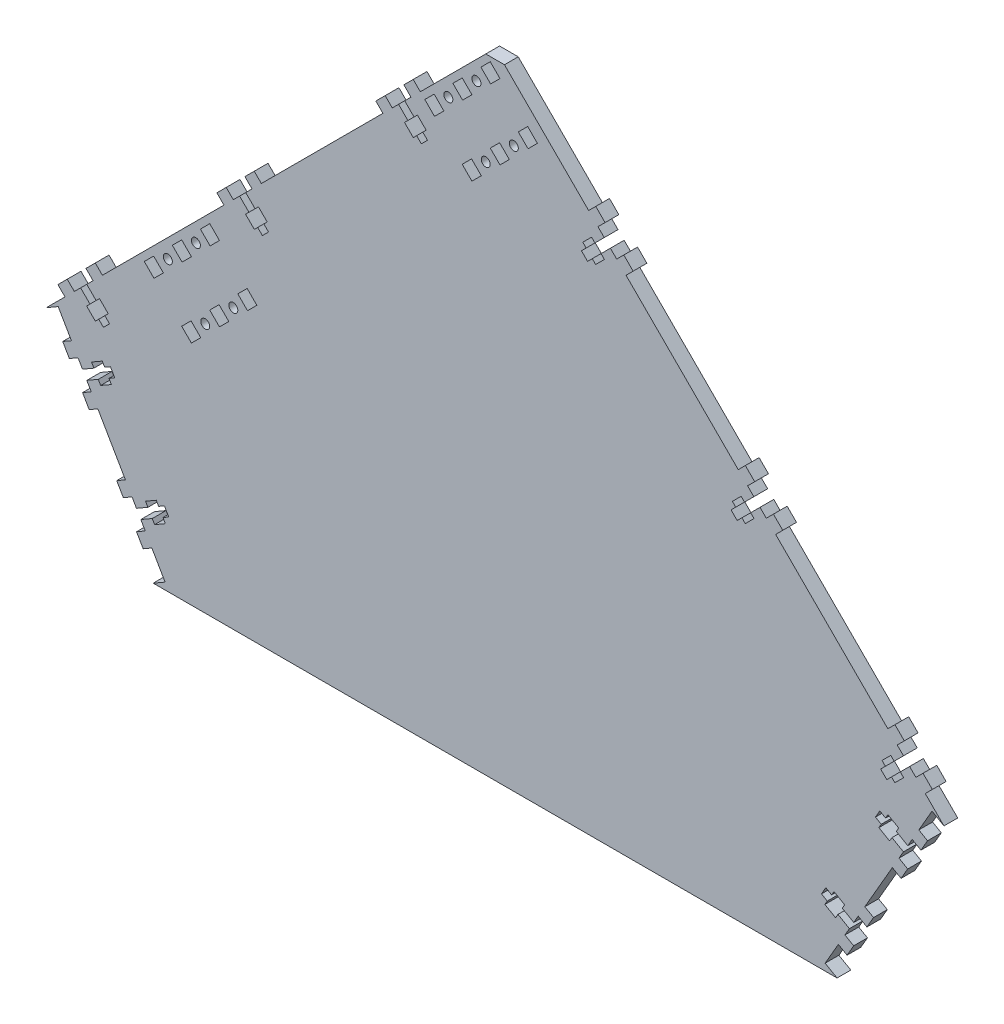
from build123d import *

# Parameters (mm, degrees)
BOSS_EXTRUDE1_DEPTH                               = 6.604
SKETCH8_R                                         = 2.15265
CUT_EXTRUDE4_DEPTH                                = 374.05550758
MOVE_FACE2_BY                                     = 0.00254
CUT_EXTRUDE2_DEPTH                                = 374.058010856
CUT_EXTRUDE3_DEPTH                                = 370.403031682
BOSS_EXTRUDE2_DEPTH                               = 6.604
CSK_FOR_8_FLAT_HEAD_SOCKET_CAP_SCREW1_D           = 4.3053
CSK_FOR_8_FLAT_HEAD_SOCKET_CAP_SCREW1_CSINK_D     = 9.1186
CSK_FOR_8_FLAT_HEAD_SOCKET_CAP_SCREW1_CSINK_ANGLE = 82


with BuildPart() as part:
    # Sketch1 → Boss-Extrude1 (new body)
    with BuildSketch(Plane.XY):
        Polygon((0, 304.426146906), (215.526146906, 88.9), (164.199707975, 0), (0, 0), (-164.199707975, 0), (-215.526146906, 88.9), align=None)
    extrude(amount=BOSS_EXTRUDE1_DEPTH)

    # Sketch8 → Cut-Extrude4 (cut, through all)
    with BuildSketch(Plane.XY.offset(6.604)):
        with Locations((-22.450640303, 272.995250482)):
            Circle(SKETCH8_R)
        with Locations((-8.980256121, 286.465634664)):
            Circle(SKETCH8_R)
        with Locations((-4.490128061, 255.03473824)):
            Circle(SKETCH8_R)
        with Locations((8.980256121, 268.505122421)):
            Circle(SKETCH8_R)
        with Locations((-157.154482119, 138.291408666)):
            Circle(SKETCH8_R)
        with Locations((-143.684097937, 151.761792847)):
            Circle(SKETCH8_R)
        with Locations((-139.193969877, 120.330896424)):
            Circle(SKETCH8_R)
        with Locations((-125.723585695, 133.801280605)):
            Circle(SKETCH8_R)
        Polygon((-20.295378834, 279.820245134), (-15.805250773, 284.310373194), (-11.13551759, 279.640640012), (-15.625645651, 275.150511951), align=None)
        Polygon((-33.765763015, 266.349860952), (-29.275634955, 270.839989013), (-24.605901772, 266.17025583), (-29.096029832, 261.680127769), align=None)
        Polygon((-2.155261469, 288.620896133), (2.334866591, 293.111024193), (-2.334866591, 297.780757376), (-6.824994652, 293.290629316), align=None)
        Polygon((-2.334866591, 261.859732892), (2.155261469, 266.349860952), (6.824994652, 261.680127769), (2.334866591, 257.189999709), align=None)
        Polygon((-15.805250773, 248.38934871), (-11.315122713, 252.879476771), (-6.64538953, 248.209743588), (-11.13551759, 243.719615527), align=None)
        Polygon((15.805250773, 270.66038389), (20.295378834, 275.150511951), (15.625645651, 279.820245134), (11.13551759, 275.330117073), align=None)
        Polygon((-154.99922065, 145.116403318), (-150.509092589, 149.606531378), (-145.839359406, 144.936798195), (-150.329487467, 140.446670135), align=None)
        Polygon((-168.469604831, 131.646019136), (-163.979476771, 136.136147197), (-159.309743588, 131.466414014), (-163.799871648, 126.976285953), align=None)
        Polygon((-136.859103285, 153.917054317), (-132.368975225, 158.407182377), (-137.038708408, 163.07691556), (-141.528836468, 158.586787499), align=None)
        Polygon((-137.038708408, 127.155891076), (-132.548580347, 131.646019136), (-127.878847164, 126.976285953), (-132.368975225, 122.486157893), align=None)
        Polygon((-150.509092589, 113.685506894), (-146.018964529, 118.175634955), (-141.349231346, 113.505901772), (-145.839359406, 109.015773711), align=None)
        Polygon((-118.898591043, 135.956542074), (-114.408462982, 140.446670135), (-119.078196165, 145.116403318), (-123.568324226, 140.626275257), align=None)
    extrude(amount=-CUT_EXTRUDE4_DEPTH, mode=Mode.SUBTRACT)

    # Move Face2: a face moved outward by 0.00254
    extrude(part.faces().sort_by_distance((107.763073453, 196.663073453, 3.302))[0], amount=MOVE_FACE2_BY, dir=(0.707106781, 0.707106781, 0))

    # Sketch3 → Cut-Extrude2 (cut, through all)
    with BuildSketch(Plane.XY.offset(6.604)):
        Polygon((-209.806915139, 92.202), (-215.526146906, 88.9), (-164.199707975, 0), (-158.480476208, 3.302), align=None)
        Polygon((158.480476208, 3.302), (209.806915139, 92.202), (215.526146906, 88.9), (164.199707975, 0), align=None)
        Polygon((0.001796051, 304.427942957), (-4.488332009, 299.937814896), (4.491924112, 299.937814896), align=None)
    extrude(amount=-CUT_EXTRUDE2_DEPTH, mode=Mode.SUBTRACT)

    # Sketch6 → Cut-Extrude3 (cut, through all)
    with BuildSketch(Plane.XY.offset(6.604)):
        Polygon((-38.938390541, 256.507500244), (-43.428518601, 260.997628304), (-46.374042609, 258.052104296), (-41.883914549, 253.561976236), (-43.50036065, 251.945530134), (-39.297600786, 247.742770269), (-37.681154684, 249.359216371), (-35.418130141, 247.096191829), (-32.472606134, 250.041715836), (-34.735630676, 252.304740379), (-33.119184575, 253.921186481), (-37.321944439, 258.123946345), align=None)
        Polygon((-115.27056757, 180.175323215), (-119.760695631, 184.665451275), (-122.706219638, 181.719927267), (-118.216091578, 177.229799207), (-119.83253768, 175.613353105), (-115.629777815, 171.41059324), (-114.013331713, 173.027039342), (-111.750307171, 170.7640148), (-108.804783163, 173.709538807), (-111.067807705, 175.97256335), (-109.451361604, 177.589009452), (-113.654121468, 181.791769316), align=None)
        Polygon((-191.602744599, 103.843146185), (-196.09287266, 108.333274246), (-199.038396667, 105.387750238), (-194.548268607, 100.897622178), (-196.164714709, 99.281176076), (-191.961954844, 95.078416211), (-190.345508742, 96.694862313), (-188.0824842, 94.431837771), (-185.136960192, 97.377361778), (-187.399984734, 99.640386321), (-185.783538633, 101.256832423), (-189.986298497, 105.459592287), align=None)
        Polygon((-192.649053825, 75.183712455), (-198.148315139, 72.008712455), (-196.065515139, 68.401197033), (-190.566253825, 71.576197033), (-189.423253825, 69.59646296), (-184.275945235, 72.56826296), (-185.418945235, 74.547997033), (-182.647317533, 76.148197033), (-184.730117533, 79.755712455), (-187.501745235, 78.155512455), (-188.644745235, 80.135246528), (-193.792053825, 77.163446528), align=None)
        Polygon((-166.722614894, 30.277802967), (-172.221876208, 27.102802967), (-170.139076208, 23.495287545), (-164.639814894, 26.670287545), (-163.496814894, 24.690553472), (-158.349506304, 27.662353472), (-159.492506304, 29.642087545), (-156.720878602, 31.242287545), (-158.803678602, 34.849802967), (-161.575306304, 33.249602967), (-162.718306304, 35.22933704), (-167.865614894, 32.25753704), align=None)
        Polygon((158.349506304, 27.662353472), (163.496814894, 24.690553472), (164.639814894, 26.670287545), (170.139076208, 23.495287545), (172.221876208, 27.102802967), (166.722614894, 30.277802967), (167.865614894, 32.25753704), (162.718306304, 35.22933704), (161.575306304, 33.249602967), (158.803678602, 34.849802967), (156.720878602, 31.242287545), (159.492506304, 29.642087545), align=None)
        Polygon((198.148315139, 72.008712455), (192.649053825, 75.183712455), (193.792053825, 77.163446528), (188.644745235, 80.135246528), (187.501745235, 78.155512455), (184.730117533, 79.755712455), (182.647317533, 76.148197033), (185.418945235, 74.547997033), (184.275945235, 72.56826296), (189.423253825, 69.59646296), (190.566253825, 71.576197033), (196.065515139, 68.401197033), align=None)
        Polygon((187.401299535, 99.642663622), (185.138274993, 97.37963908), (188.083799, 94.434115072), (190.346823543, 96.697139615), (191.963269645, 95.080693513), (196.166029509, 99.283453378), (194.549583408, 100.899899479), (199.039711468, 105.39002754), (196.09418746, 108.335551548), (191.6040594, 103.845423487), (189.987613298, 105.461869589), (185.784853433, 101.259109724), align=None)
        Polygon((124.252138492, 180.177600516), (119.762010431, 175.687472456), (118.14556433, 177.303918558), (113.942804465, 173.101158693), (115.559250567, 171.484712591), (113.296226024, 169.221688049), (116.241750032, 166.276164041), (118.504774574, 168.539188583), (120.121220676, 166.922742482), (124.323980541, 171.125502346), (122.707534439, 172.741948448), (127.1976625, 177.232076509), align=None)
        Polygon((41.454177056, 241.063737017), (44.399701063, 238.118213009), (46.662725606, 240.381237552), (48.279171708, 238.76479145), (52.481931572, 242.967551315), (50.86548547, 244.583997417), (55.355613531, 249.074125477), (52.410089523, 252.019649485), (47.919961463, 247.529521424), (46.303515361, 249.145967526), (42.100755496, 244.943207661), (43.717201598, 243.32676156), align=None)
    extrude(amount=-CUT_EXTRUDE3_DEPTH, mode=Mode.SUBTRACT)

    # Sketch7 → Boss-Extrude2 (add)
    with BuildSketch(Plane.XY.offset(6.604)):
        Polygon((-39.33352181, 271.917619747), (-35.921024484, 268.505122421), (-40.411152545, 264.014994361), (-43.823649871, 267.427491687), align=None)
        Polygon((-49.391408666, 255.03473824), (-52.803905992, 258.447235566), (-57.294034052, 253.957107505), (-53.881536726, 250.544610179), align=None)
        Polygon((-115.665698839, 195.585442718), (-112.253201513, 192.172945392), (-116.743329574, 187.682817332), (-120.1558269, 191.095314658), align=None)
        Polygon((-125.723585695, 178.702561211), (-129.136083021, 182.115058537), (-133.626211082, 177.624930476), (-130.213713756, 174.21243315), align=None)
        Polygon((-191.997875868, 119.253265689), (-188.585378542, 115.840768363), (-193.075506603, 111.350640303), (-196.488003929, 114.763137629), align=None)
        Polygon((-202.055762724, 102.370384182), (-205.46826005, 105.782881508), (-209.958388111, 101.292753447), (-206.545890785, 97.880256121), align=None)
        Polygon((-207.636353738, 78.790477372), (-203.456915139, 81.203477372), (-200.281915139, 75.704216058), (-204.461353738, 73.291216058), align=None)
        Polygon((-193.931915139, 64.70569343), (-198.111353738, 62.29269343), (-194.936353738, 56.793432116), (-190.756915139, 59.206432116), align=None)
        Polygon((-178.534914807, 28.38530657), (-181.709914807, 33.884567884), (-177.530476208, 36.297567884), (-174.355476208, 30.79830657), align=None)
        Polygon((-172.184914807, 17.386783942), (-169.009914807, 11.887522628), (-164.830476208, 14.300522628), (-168.005476208, 19.799783942), align=None)
        Polygon((169.009914807, 11.887522628), (164.830476208, 14.300522628), (168.005476208, 19.799783942), (172.184914807, 17.386783942), align=None)
        Polygon((181.709914807, 33.884567884), (177.530476208, 36.297567884), (174.355476208, 30.79830657), (178.534914807, 28.38530657), align=None)
        Polygon((193.931915139, 64.70569343), (198.111353738, 62.29269343), (194.936353738, 56.793432116), (190.756915139, 59.206432116), align=None)
        Polygon((207.636353738, 78.790477372), (203.456915139, 81.203477372), (200.281915139, 75.704216058), (204.461353738, 73.291216058), align=None)
        Polygon((209.959702911, 101.295030749), (206.547205585, 97.882533423), (202.057077525, 102.372661483), (205.469574851, 105.785158809), align=None)
        Polygon((193.076821404, 111.352917604), (196.48931873, 114.76541493), (191.999190669, 119.255542991), (188.586693343, 115.843045665), align=None)
        Polygon((130.215028556, 174.214710452), (133.627525882, 177.627207778), (138.117653943, 173.137079717), (134.705156617, 169.724582391), align=None)
        Polygon((121.234772435, 183.194966573), (124.647269761, 186.607463899), (120.157141701, 191.097591959), (116.744644375, 187.685094633), align=None)
        Polygon((48.315092732, 262.939640928), (44.902595406, 259.527143602), (49.392723467, 255.037015541), (52.805220793, 258.449512867), align=None)
        Polygon((58.372979588, 246.05675942), (61.785476914, 249.469256746), (66.275604974, 244.979128686), (62.863107648, 241.56663136), align=None)
    extrude(amount=-BOSS_EXTRUDE2_DEPTH)

    # CSK for #8 Flat Head Socket Cap Screw1 (through all)
    with Locations(Plane(origin=(0, 0, 0), x_dir=(-1, 0, 0), z_dir=(0, 0, -1))):
        with Locations((8.980256121, 286.465634664), (22.450640303, 272.995250482), (4.490128061, 255.03473824), (-8.980256121, 268.505122421), (143.684097937, 151.761792847), (157.154482119, 138.291408666), (125.723585695, 133.801280605), (139.193969877, 120.330896424)):
            CounterSinkHole(CSK_FOR_8_FLAT_HEAD_SOCKET_CAP_SCREW1_D / 2, CSK_FOR_8_FLAT_HEAD_SOCKET_CAP_SCREW1_CSINK_D / 2, counter_sink_angle=CSK_FOR_8_FLAT_HEAD_SOCKET_CAP_SCREW1_CSINK_ANGLE)


solid = part.part
